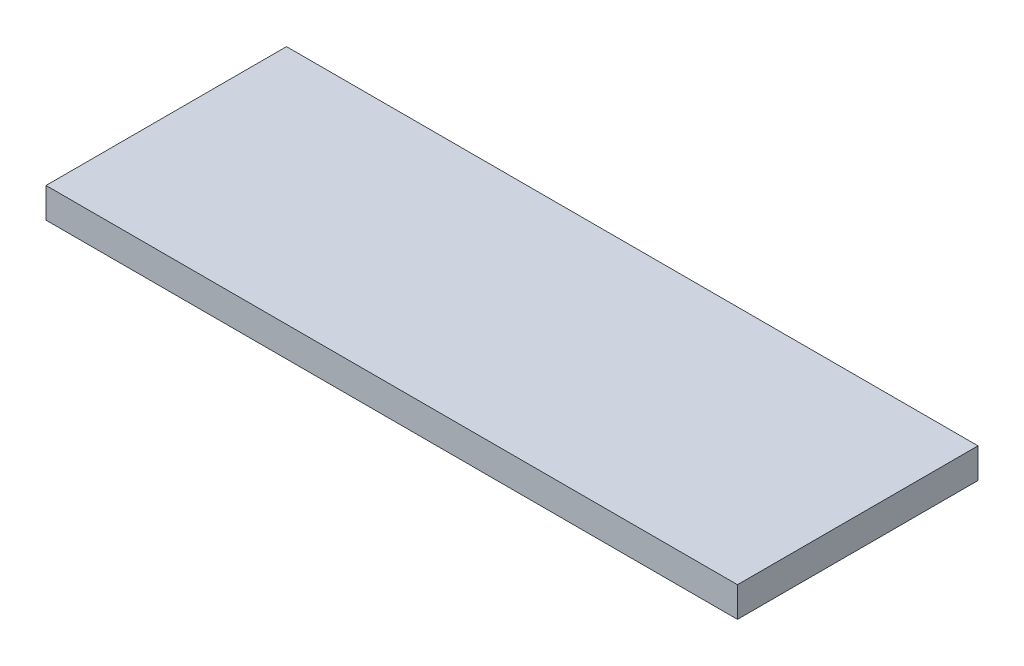
from build123d import *

# Parameters (mm, degrees)
SKETCH1_W           = 115
SKETCH1_H           = 40
BOSS_EXTRUDE1_DEPTH = 5


with BuildPart() as part:
    # Sketch1 → Boss-Extrude1 (new body)
    with BuildSketch(Plane(origin=(0, 0, 0), x_dir=(1, 0, 0), z_dir=(0, 1, 0))):
        Rectangle(SKETCH1_W, SKETCH1_H)
    extrude(amount=BOSS_EXTRUDE1_DEPTH)


solid = part.part
